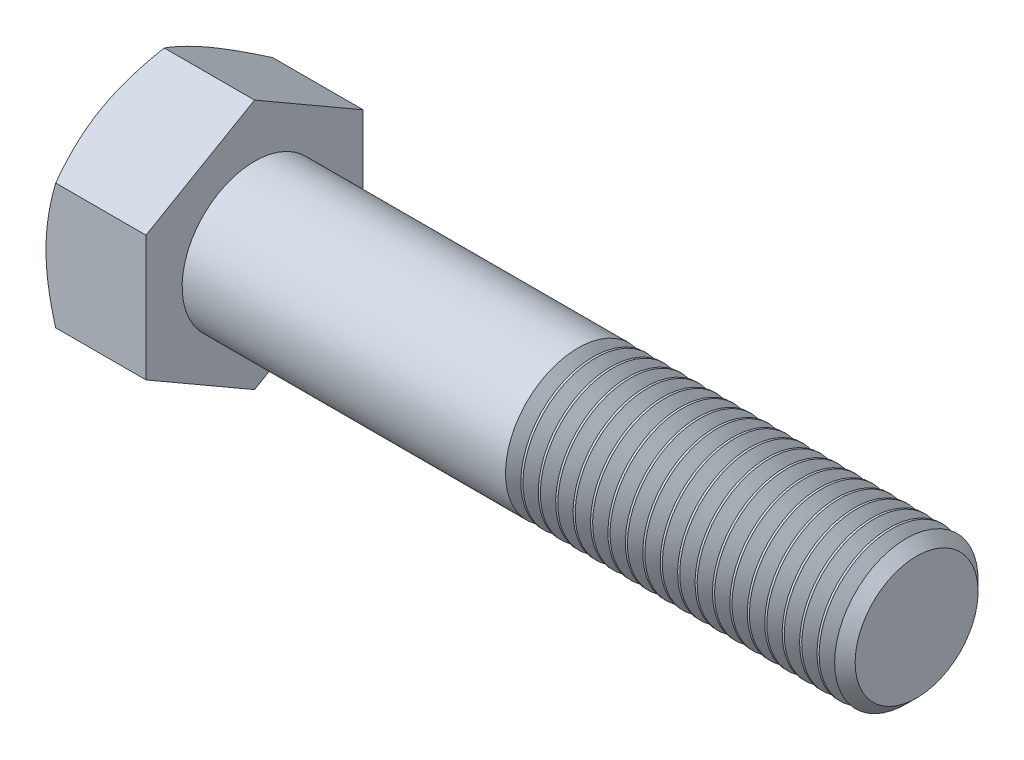
from build123d import *

# Parameters (mm, degrees)
BASEHEAD_DEPTH  = 15.3416
THDSCHPAT_COUNT = 19
THDSCHPAT_PITCH = 2.673684211


with BuildPart() as part:
    # Sketch1 → BaseHead (new body)
    with BuildSketch(Plane(origin=(0, 0, 0), x_dir=(0, 0, -1), z_dir=(1, 0, 0))):
        Polygon((16.6624, 9.620041125), (16.6624, -9.620041125), (0, -19.240082251), (-16.6624, -9.620041125), (-16.6624, 9.620041125), (0, 19.240082251), align=None)
    extrude(amount=BASEHEAD_DEPTH)

    # BodySke → BaseBody (revolve)
    with BuildSketch(Plane.XY):
        Polygon((0, 0), (116.9416, 0), (116.9416, 9.43229), (115.26139, 11.1125), (0, 11.1125), align=None)
    revolve(axis=Axis((0, 0, 0), (1, 0, 0)))

    # Sketch3 → HeadChamfer (revolve, cut)
    with BuildSketch(Plane.XY):
        Polygon((0, 16.6624), (5.154399751, 25.590082251), (5.154399751, 31.940082251), (-12.7, 31.940082251), (-12.7, 16.6624), align=None)
    revolve(axis=Axis((0, 0, 0), (1, 0, 0)), mode=Mode.SUBTRACT)

    # ThdSchSke → ThreadSchematic (revolve, cut)
    with BuildSketch(Plane.XY):
        Polygon((66.1416, -9.43229), (64.965104292, -11.1125), (64.965104292, -13.890625), (67.318095708, -13.890625), (67.318095708, -11.1125), align=None)
    threadschematic = revolve(axis=Axis((-3.175, 0, 0), (1, 0, 0)), mode=Mode.SUBTRACT)

    # ThdSchPat: ThreadSchematic ×19
    with Locations(*[(i * THDSCHPAT_PITCH, 0, 0) for i in range(1, THDSCHPAT_COUNT)]):
        add(threadschematic, mode=Mode.SUBTRACT)


solid = part.part
